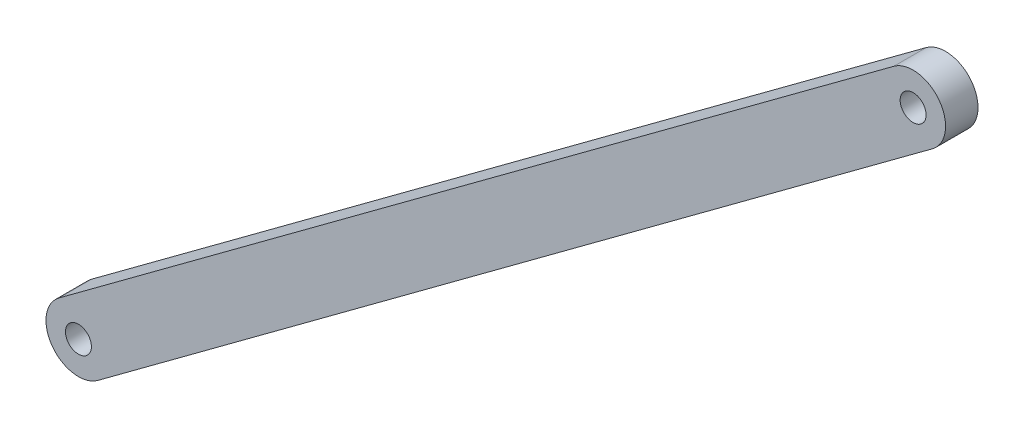
from build123d import *

# Parameters (mm, degrees)
BOSS_EXTRUDE1_START = -5
SKETCH1_R           = 2
BOSS_EXTRUDE1_DEPTH = 5


with BuildPart() as part:
    # Sketch1 → Boss-Extrude1 (new body)
    with BuildSketch(Plane.XY.offset(BOSS_EXTRUDE1_START)):
        with BuildLine():
            Line((-256.919150515, 65.08441618), (-128.325307812, 160.287481355))
            ThreePointArc((-128.325307812, 160.287481355), (-121.33165444, 159.244019557), (-122.375116238, 152.250366186))
            Line((-122.375116238, 152.250366186), (-250.968958942, 57.047301011))
            ThreePointArc((-250.968958942, 57.047301011), (-257.962612313, 58.090762809), (-256.919150515, 65.08441618))
        make_face()
        with Locations((-125.350212025, 156.26892377)):
            Circle(SKETCH1_R, mode=Mode.SUBTRACT)
        with Locations((-253.944054729, 61.065858595)):
            Circle(SKETCH1_R, mode=Mode.SUBTRACT)
    extrude(amount=-BOSS_EXTRUDE1_DEPTH)


solid = part.part
